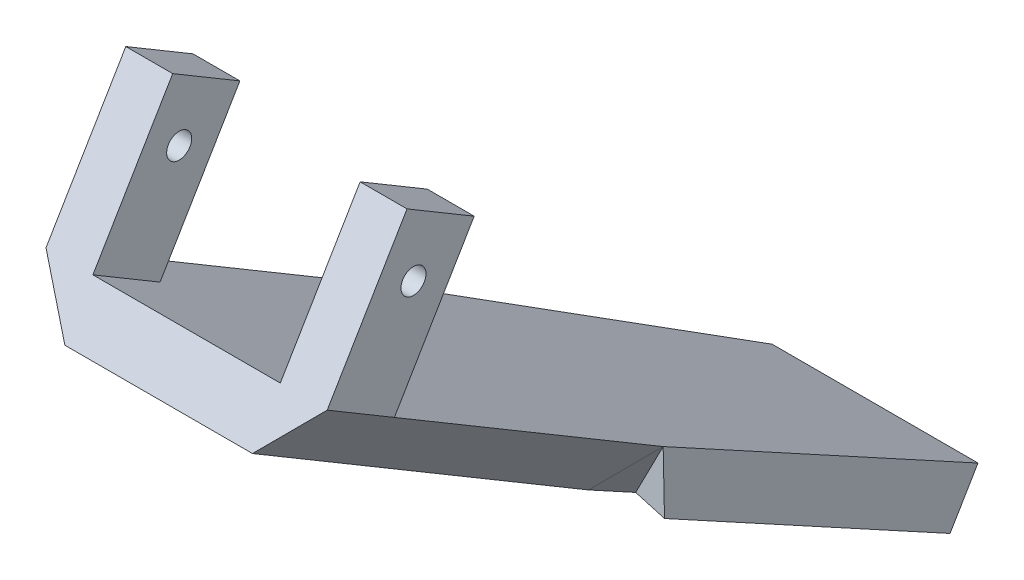
from build123d import *

# Parameters (mm, degrees)
BOSS_EXTRUDE1_DEPTH = 8.89
SKETCH9_W           = 38.1
SKETCH9_H           = 170.494756514
CUT_EXTRUDE1_DEPTH  = 10.16
BOSS_EXTRUDE2_DEPTH = 63.5
SKETCH12_W          = 7.62
SKETCH12_H          = 12.7
BOSS_EXTRUDE3_DEPTH = 25.4
SKETCH13_R          = 2.031999997
CUT_EXTRUDE2_DEPTH  = 46.699791471


with BuildPart() as part:
    # Sketch2 → Boss-Extrude1 (new body)
    with BuildSketch(Plane(origin=(0, 107.565160262, -63.883098153), x_dir=(1, 0, 0), z_dir=(0, -0.859797598, 0.510634988))):
        Polygon((-16.72668145, 3.22686704), (-22.849895735, 69.859735371), (22.849895735, 69.859735371), (16.72668145, 3.22686704), align=None)
    extrude(amount=BOSS_EXTRUDE1_DEPTH)

    # Sketch9 → Cut-Extrude1 (cut)
    with BuildSketch(Plane(origin=(52.068196995, 40.765068024, -18.64540373), x_dir=(0.369989021, -0.048221617, 0.927783811), z_dir=(-0.75783864, -0.59332463, 0.27137885))):
        with Locations((0.146468301, 41.148554402)):
            Rectangle(SKETCH9_W, SKETCH9_H)
    cut_extrude1 = extrude(amount=CUT_EXTRUDE1_DEPTH, mode=Mode.SUBTRACT)

    # Mirror1: Cut-Extrude1 across plane
    add(cut_extrude1.mirror(Plane.ZY), mode=Mode.SUBTRACT)

    # Sketch11 → Boss-Extrude2 (add)
    with BuildSketch(Plane(origin=(0, 35.672825136, 60.065232647), x_dir=(1, 0, 0), z_dir=(0, 0.510634988, 0.859797598))):
        Polygon((-22.849895735, 125.105211449), (-15.24, 116.215211449), (15.24, 116.215211449), (22.849895735, 125.105211449), align=None)
    extrude(amount=BOSS_EXTRUDE2_DEPTH)

    # Sketch12 → Boss-Extrude3 (add)
    with BuildSketch(Plane(origin=(0, 107.565160262, -63.883098153), x_dir=(-1, 0, 0), z_dir=(0, 0.859797598, -0.510634988))):
        with Locations((-19.039895735, 127.009735371)):
            Rectangle(SKETCH12_W, SKETCH12_H)
    boss_extrude3 = extrude(amount=BOSS_EXTRUDE3_DEPTH)

    # Mirror2: Boss-Extrude3 across plane
    add(boss_extrude3.mirror(Plane(origin=(0, 0, 0), x_dir=(0, 0, 1), z_dir=(1, 0, 0))))

    # Sketch13 → Cut-Extrude2 (cut, through all)
    with BuildSketch(Plane.ZY.offset(22.849895735)):
        with Locations((36.759282263, 186.834421892)):
            Circle(SKETCH13_R)
    extrude(amount=-CUT_EXTRUDE2_DEPTH, mode=Mode.SUBTRACT)


solid = part.part
